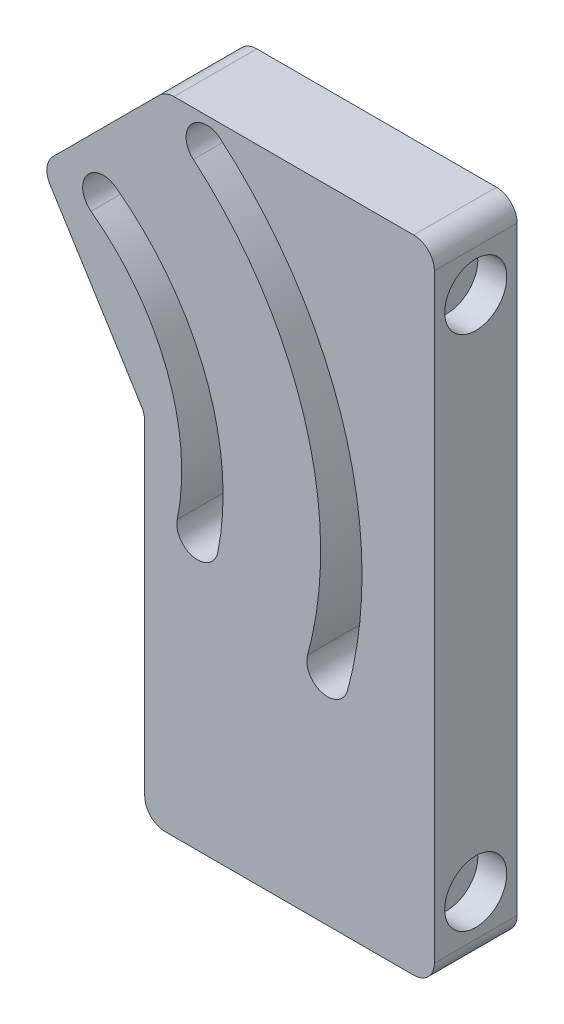
from build123d import *

# Parameters (mm, degrees)
BOSS_EXTRUDE1_DEPTH = 25.4
SKETCH2_R           = 9.525
CUT_EXTRUDE1_DEPTH  = 8.89
CUT_EXTRUDE2_DEPTH  = 26.4
CUT_EXTRUDE3_DEPTH  = 26.4
FILLET1_R           = 6.35


with BuildPart() as part:
    # Sketch1 → Boss-Extrude1 (new body)
    with BuildSketch(Plane.XY):
        Polygon((0, 0), (0, -196.747553987), (-88.9, -196.747553987), (-120.65, -158.647553987), (-120.65, -38.1), (-82.55, 0), align=None)
    extrude(amount=BOSS_EXTRUDE1_DEPTH)

    # Sketch2 → Cut-Extrude1 (cut)
    with BuildSketch(Plane(origin=(0, 0, 0), x_dir=(0, 0, -1), z_dir=(1, 0, 0))):
        with Locations((-12.7, -19.05)):
            Circle(SKETCH2_R)
        with Locations((-12.7, -177.697553987)):
            Circle(SKETCH2_R)
    extrude(amount=-CUT_EXTRUDE1_DEPTH, mode=Mode.SUBTRACT)

    # Sketch3 → Cut-Extrude2 (cut, through all)
    with BuildSketch(Plane.XY.offset(25.4)):
        with BuildLine():
            ThreePointArc((-66.460403821, -114.415261768), (-70.27820982, -69.131547214), (-97.829036835, -32.990955392))
            ThreePointArc((-97.829036835, -32.990955392), (-106.709044608, -34.329036835), (-105.370963165, -43.209044608))
            ThreePointArc((-105.370963165, -43.209044608), (-82.129181306, -73.697122187), (-78.908493442, -111.898306307))
            ThreePointArc((-78.908493442, -111.898306307), (-73.942926362, -119.380828848), (-66.460403821, -114.415261768))
        make_face()
        with BuildLine():
            ThreePointArc((-26.672013645, -131.277107348), (-27.661158876, -61.974397079), (-65.731714588, -4.056551411))
            ThreePointArc((-65.731714588, -4.056551411), (-74.683448589, -4.771714588), (-73.968285412, -13.723448589))
            ThreePointArc((-73.968285412, -13.723448589), (-39.80183232, -65.701869188), (-38.914123079, -127.897646353))
            ThreePointArc((-38.914123079, -127.897646353), (-34.48279886, -135.708431567), (-26.672013645, -131.277107348))
        make_face()
    extrude(amount=-CUT_EXTRUDE2_DEPTH, mode=Mode.SUBTRACT)

    # Sketch4 → Cut-Extrude3 (cut, through all)
    with BuildSketch(Plane.XY.offset(25.4)):
        Polygon((-120.65, -38.1), (-88.9, -88.9), (-88.9, -196.747553987), (-120.65, -158.647553987), align=None)
    extrude(amount=-CUT_EXTRUDE3_DEPTH, mode=Mode.SUBTRACT)

    # Fillet1
    fillet1_edges = [part.edges().sort_by_distance(p)[0] for p in [
        (-88.9, -196.747553987, 12.7),
        (-120.65, -38.1, 12.7),
        (-82.55, 0, 12.7),
        (0, 0, 12.7),
        (0, -196.747553987, 12.7),
        (-88.9, -88.9, 12.7),
    ]]
    fillet(fillet1_edges, radius=FILLET1_R)


solid = part.part
